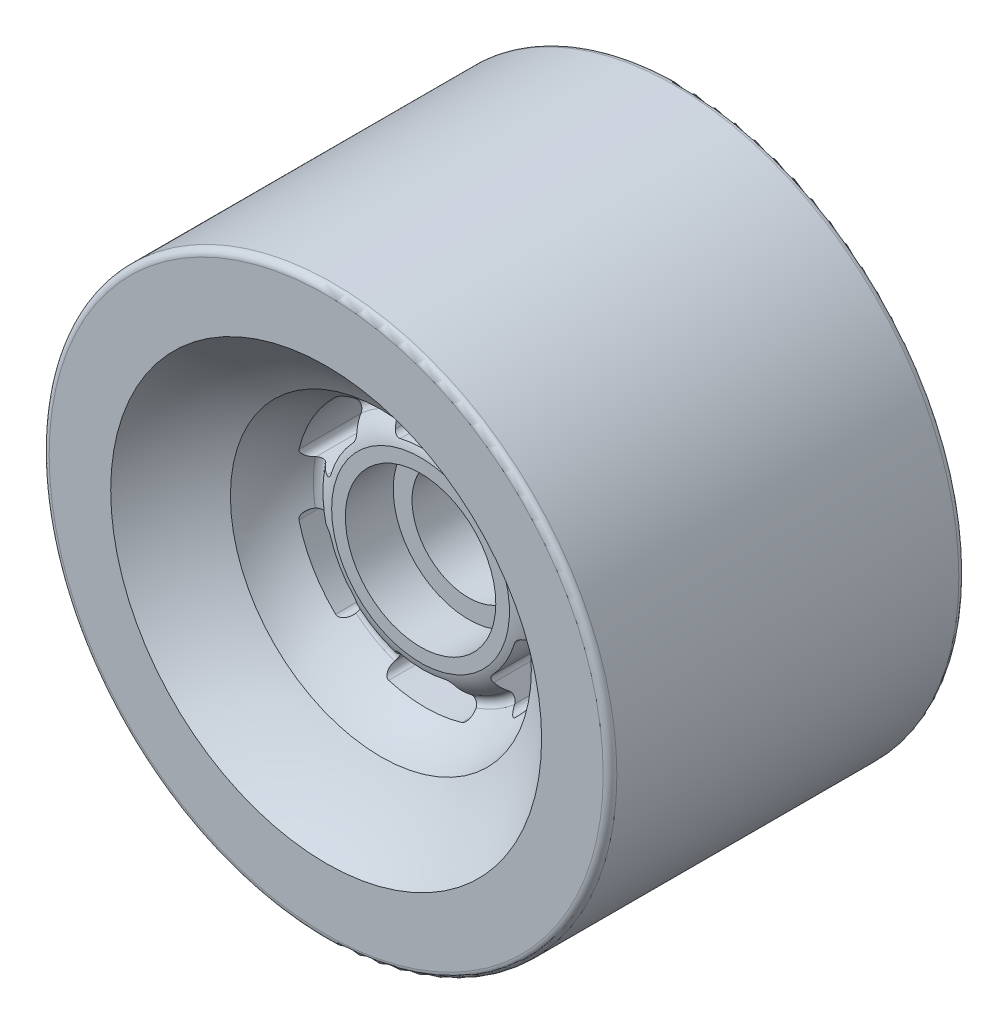
from build123d import *

# Parameters (mm, degrees)
SKETCH1_R           = 41.5
BOSS_EXTRUDE1_DEPTH = 26
CUT_EXTRUDE1_DEPTH  = 45
SKETCH3_R           = 11
CUT_EXTRUDE2_DEPTH  = 7
SKETCH10_R          = 8.25
CUT_EXTRUDE3_DEPTH  = 32.2000001
FILLET1_R           = 1


with BuildPart() as part:
    # Sketch1 → Boss-Extrude1 (new body, symmetric)
    with BuildSketch(Plane.XY):
        Circle(SKETCH1_R)
    extrude(amount=BOSS_EXTRUDE1_DEPTH, both=True)

    # Sketch7 → Cut-Revolve1 (revolve, cut)
    with BuildSketch(Plane(origin=(0, 0, 0), x_dir=(0, 0, -1), z_dir=(1, 0, 0))):
        with BuildLine():
            Line((-18, 22), (-18, 0))
            Line((-18, 0), (-26, 0))
            Line((-26, 0), (-26, 31.5))
            ThreePointArc((-26, 31.5), (-21.563415917, 27.117649754), (-18, 22))
        make_face()
    cut_revolve1 = revolve(axis=Axis((0, 0, 26), (0, 0, -1)), mode=Mode.SUBTRACT)

    # Sketch9 → Cut-Extrude1 (cut, through all)
    with BuildSketch(Plane.XY.offset(18)):
        with BuildLine():
            Line((4.378078628, 14.083054623), (5.930952013, 16.772710223))
            ThreePointArc((5.930952013, 16.772710223), (5.99322718, 17.644540896), (5.34631142, 18.232305235))
            ThreePointArc((5.34631142, 18.232305235), (0, 19), (-5.34631142, 18.232305235))
            ThreePointArc((-5.34631142, 18.232305235), (-5.99322718, 17.644540896), (-5.930952013, 16.772710223))
            Line((-5.930952013, 16.772710223), (-4.378078628, 14.083054623))
            ThreePointArc((-4.378078628, 14.083054623), (-3.906470321, 13.664123095), (-3.277916343, 13.610850982))
            ThreePointArc((-3.277916343, 13.610850982), (0, 14), (3.277916343, 13.610850982))
            ThreePointArc((3.277916343, 13.610850982), (3.906470321, 13.664123095), (4.378078628, 14.083054623))
        make_face()
        with BuildLine():
            Line((10.007243753, 10.833054623), (11.560117137, 13.522710223))
            ThreePointArc((11.560117137, 13.522710223), (12.284007064, 14.012557437), (13.116483793, 13.746194124))
            ThreePointArc((13.116483793, 13.746194124), (16.454482672, 9.5), (18.462795214, 4.486111111))
            ThreePointArc((18.462795214, 4.486111111), (18.277234244, 3.631983459), (17.49106915, 3.25))
            Line((17.49106915, 3.25), (14.385322381, 3.25))
            ThreePointArc((14.385322381, 3.25), (13.786712881, 3.448959011), (13.426300889, 3.966666667))
            ThreePointArc((13.426300889, 3.966666667), (12.124355653, 7), (10.148384546, 9.644184315))
            ThreePointArc((10.148384546, 9.644184315), (9.88024256, 10.215164084), (10.007243753, 10.833054623))
        make_face()
        with BuildLine():
            Line((14.385322381, -3.25), (17.49106915, -3.25))
            ThreePointArc((17.49106915, -3.25), (18.277234244, -3.631983459), (18.462795214, -4.486111111))
            ThreePointArc((18.462795214, -4.486111111), (16.454482672, -9.5), (13.116483793, -13.746194124))
            ThreePointArc((13.116483793, -13.746194124), (12.284007064, -14.012557437), (11.560117137, -13.522710223))
            Line((11.560117137, -13.522710223), (10.007243753, -10.833054623))
            ThreePointArc((10.007243753, -10.833054623), (9.88024256, -10.215164084), (10.148384546, -9.644184315))
            ThreePointArc((10.148384546, -9.644184315), (12.124355653, -7), (13.426300889, -3.966666667))
            ThreePointArc((13.426300889, -3.966666667), (13.786712881, -3.448959011), (14.385322381, -3.25))
        make_face()
        with BuildLine():
            Line((4.378078628, -14.083054623), (5.930952013, -16.772710223))
            ThreePointArc((5.930952013, -16.772710223), (5.99322718, -17.644540896), (5.34631142, -18.232305235))
            ThreePointArc((5.34631142, -18.232305235), (0, -19), (-5.34631142, -18.232305235))
            ThreePointArc((-5.34631142, -18.232305235), (-5.99322718, -17.644540896), (-5.930952013, -16.772710223))
            Line((-5.930952013, -16.772710223), (-4.378078628, -14.083054623))
            ThreePointArc((-4.378078628, -14.083054623), (-3.906470321, -13.664123095), (-3.277916343, -13.610850982))
            ThreePointArc((-3.277916343, -13.610850982), (0, -14), (3.277916343, -13.610850982))
            ThreePointArc((3.277916343, -13.610850982), (3.906470321, -13.664123095), (4.378078628, -14.083054623))
        make_face()
        with BuildLine():
            Line((-10.007243753, -10.833054623), (-11.560117137, -13.522710223))
            ThreePointArc((-11.560117137, -13.522710223), (-12.284007064, -14.012557437), (-13.116483793, -13.746194124))
            ThreePointArc((-13.116483793, -13.746194124), (-16.454482672, -9.5), (-18.462795214, -4.486111111))
            ThreePointArc((-18.462795214, -4.486111111), (-18.277234244, -3.631983459), (-17.49106915, -3.25))
            Line((-17.49106915, -3.25), (-14.385322381, -3.25))
            ThreePointArc((-14.385322381, -3.25), (-13.786712881, -3.448959011), (-13.426300889, -3.966666667))
            ThreePointArc((-13.426300889, -3.966666667), (-12.124355653, -7), (-10.148384546, -9.644184315))
            ThreePointArc((-10.148384546, -9.644184315), (-9.88024256, -10.215164084), (-10.007243753, -10.833054623))
        make_face()
        with BuildLine():
            Line((-14.385322381, 3.25), (-17.49106915, 3.25))
            ThreePointArc((-17.49106915, 3.25), (-18.277234244, 3.631983459), (-18.462795214, 4.486111111))
            ThreePointArc((-18.462795214, 4.486111111), (-16.454482672, 9.5), (-13.116483793, 13.746194124))
            ThreePointArc((-13.116483793, 13.746194124), (-12.284007064, 14.012557437), (-11.560117137, 13.522710223))
            Line((-11.560117137, 13.522710223), (-10.007243753, 10.833054623))
            ThreePointArc((-10.007243753, 10.833054623), (-9.88024256, 10.215164084), (-10.148384546, 9.644184315))
            ThreePointArc((-10.148384546, 9.644184315), (-12.124355653, 7), (-13.426300889, 3.966666667))
            ThreePointArc((-13.426300889, 3.966666667), (-13.786712881, 3.448959011), (-14.385322381, 3.25))
        make_face()
    extrude(amount=-CUT_EXTRUDE1_DEPTH, mode=Mode.SUBTRACT)

    # Sketch8 → Cut-Revolve2 (revolve, cut)
    with BuildSketch(Plane(origin=(0, 0, 0), x_dir=(0, 0, -1), z_dir=(1, 0, 0))):
        with BuildLine():
            Line((-12.2, 13), (-12.2, 0))
            Line((-12.2, 0), (-18, 0))
            Line((-18, 0), (-18, 22))
            ThreePointArc((-18, 22), (-13.774777315, 20.392807862), (-10.042496246, 17.842190029))
            ThreePointArc((-10.042496246, 17.842190029), (-9.70077168, 17.049460731), (-10.10366748, 16.286001242))
            ThreePointArc((-10.10366748, 16.286001242), (-11.454212756, 14.835905893), (-12.2, 13))
        make_face()
    cut_revolve2 = revolve(axis=Axis((0, 0, 12.2), (0, 0, 1)), mode=Mode.SUBTRACT)

    # Sketch3 → Cut-Extrude2 (cut)
    with BuildSketch(Plane.XY.offset(12.2)):
        Circle(SKETCH3_R)
    cut_extrude2 = extrude(amount=-CUT_EXTRUDE2_DEPTH, mode=Mode.SUBTRACT)

    # Sketch10 → Cut-Extrude3 (cut, through all)
    with BuildSketch(Plane.XY.offset(5.2)):
        Circle(SKETCH10_R)
    extrude(amount=-CUT_EXTRUDE3_DEPTH, mode=Mode.SUBTRACT)

    # Mirror1: Cut-Revolve2, Cut-Extrude2 across plane
    add(cut_revolve2.mirror(Plane.XY), mode=Mode.SUBTRACT)
    add(cut_extrude2.mirror(Plane.XY), mode=Mode.SUBTRACT)

    # Mirror2: Cut-Revolve1 across plane
    add(cut_revolve1.mirror(Plane.XY), mode=Mode.SUBTRACT)

    # Fillet1
    fillet1_edges = [part.edges().sort_by_distance(p)[0] for p in [
        (-41.5, 0, -26),
        (-41.5, 0, 26),
    ]]
    fillet(fillet1_edges, radius=FILLET1_R)


solid = part.part
